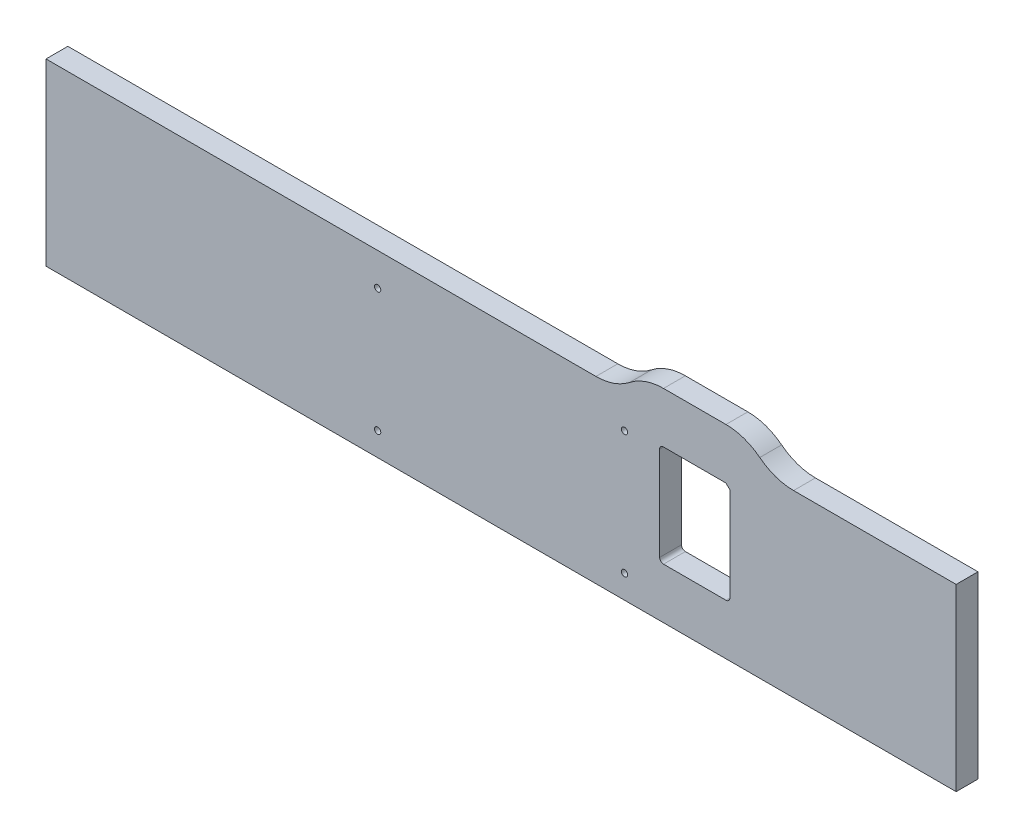
from build123d import *

# Parameters (mm, degrees)
HEADDISPLAYBRACKET_THICKNESS_DEPTH = 17.78
SKETCH3_R                          = 2.54
CUT_EXTRUDE1_DEPTH                 = 17.78


with BuildPart() as part:
    # HeadDisplayBraceOutline → HeadDisplayBracket_Thickness (new body)
    with BuildSketch(Plane.XY):
        with BuildLine():
            Line((137.16, -6013.450000001), (-603.25, -6013.450000001))
            Line((-603.25, -6013.450000001), (-603.25, -5867.400000001))
            Line((-603.25, -5867.400000001), (-155.878238141, -5867.400000001))
            ThreePointArc((-155.878238141, -5867.400000001), (-141.328560309, -5864.951302064), (-128.38193157, -5857.875))
            ThreePointArc((-128.38193157, -5857.875), (-115.435302831, -5850.798697937), (-100.885625, -5848.35))
            Line((-100.885625, -5848.35), (-50.085625, -5848.35))
            ThreePointArc((-50.085625, -5848.35), (-35.535947169, -5850.798697937), (-22.58931843, -5857.875))
            ThreePointArc((-22.58931843, -5857.875), (-9.642689691, -5864.951302063), (4.906988141, -5867.400000001))
            Line((4.906988141, -5867.400000001), (137.16, -5867.400000001))
            Line((137.16, -5867.400000001), (137.16, -6013.450000001))
        make_face()
    extrude(amount=-HEADDISPLAYBRACKET_THICKNESS_DEPTH)

    # Sketch3 → Cut-Extrude1 (cut)
    with BuildSketch(Plane.XY):
        with Locations((-333.454375, -5994.4)):
            Circle(SKETCH3_R)
        with Locations((-132.635625, -5994.4)):
            Circle(SKETCH3_R)
        with Locations((-132.635625, -5894.07)):
            Circle(SKETCH3_R)
        with Locations((-333.454375, -5894.07)):
            Circle(SKETCH3_R)
        with BuildLine():
            Line((-104.060625, -5892.8), (-104.060625, -5969))
            ThreePointArc((-104.060625, -5969), (-103.13068903, -5971.24506403), (-100.885625, -5972.175))
            Line((-100.885625, -5972.175), (-50.085625, -5972.175))
            ThreePointArc((-50.085625, -5972.175), (-47.84056097, -5971.24506403), (-46.910625, -5969))
            Line((-46.910625, -5969), (-46.910625, -5892.8))
            Line((-46.910625, -5892.8), (-50.085625, -5889.625))
            Line((-50.085625, -5889.625), (-100.885625, -5889.625))
            ThreePointArc((-100.885625, -5889.625), (-103.13068903, -5890.55493597), (-104.060625, -5892.8))
        make_face()
    extrude(amount=-CUT_EXTRUDE1_DEPTH, mode=Mode.SUBTRACT)


solid = part.part
